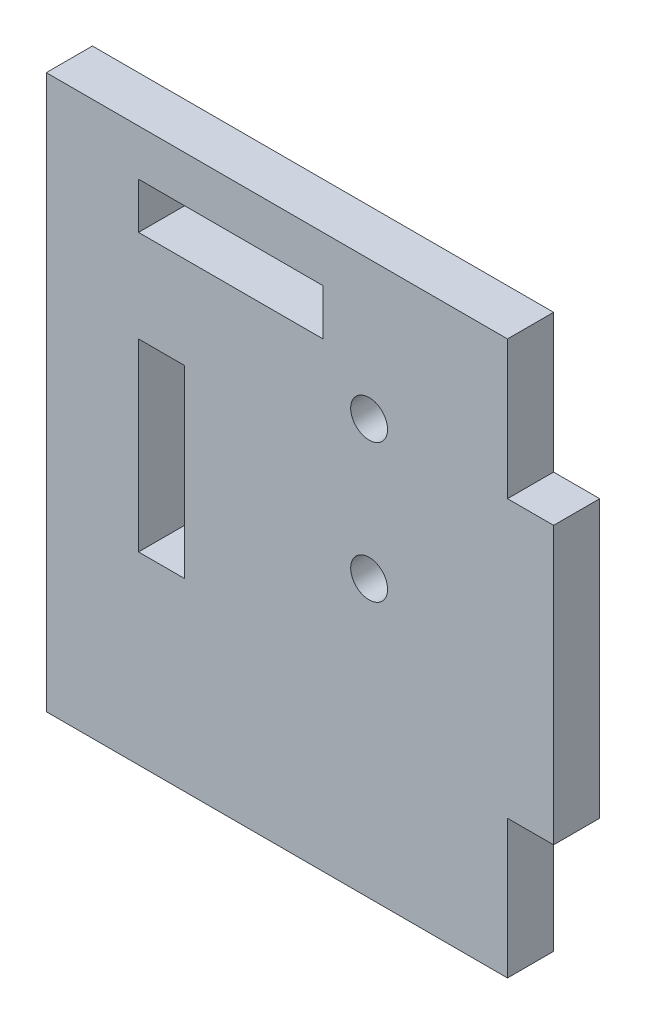
from build123d import *

# Parameters (mm, degrees)
ESQUISSE1_R        = 2
ESQUISSE1_W        = 20
ESQUISSE1_H        = 5
ESQUISSE1_W_2      = 5
ESQUISSE1_H_2      = 20
BOSS_EXTRU_1_DEPTH = 5


with BuildPart() as part:
    # Esquisse1 → Boss.-Extru.1 (new body)
    with BuildSketch(Plane.XY):
        Polygon((-55, 45), (-5, 45), (-5, 30), (0, 30), (0, 0), (-5, 0), (-5, -15), (-55, -15), align=None)
        with Locations((-20, 30)):
            Circle(ESQUISSE1_R, mode=Mode.SUBTRACT)
        with Locations((-20, 15)):
            Circle(ESQUISSE1_R, mode=Mode.SUBTRACT)
        with Locations((-35, 37.5)):
            Rectangle(ESQUISSE1_W, ESQUISSE1_H, mode=Mode.SUBTRACT)
        with Locations((-42.5, 15)):
            Rectangle(ESQUISSE1_W_2, ESQUISSE1_H_2, mode=Mode.SUBTRACT)
    extrude(amount=BOSS_EXTRU_1_DEPTH)


solid = part.part
